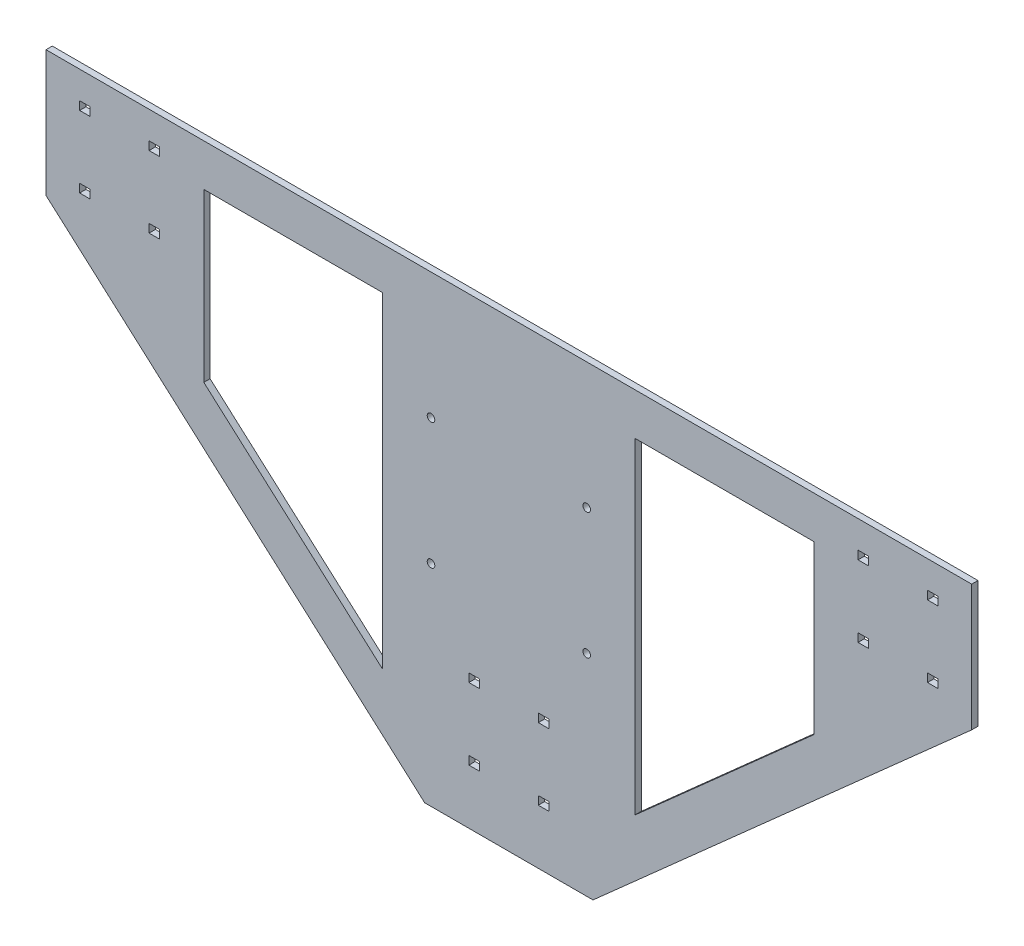
from build123d import *

# Parameters (mm, degrees)
BOSS_EXTRU_1_DEPTH      = 3
ESQUISSE2_W             = 5
ESQUISSE2_H             = 4
ENL_V_MAT_EXTRU_1_DEPTH = 3
ESQUISSE4_R             = 1.8
ENL_V_MAT_EXTRU_2_DEPTH = 3
ENL_V_MAT_EXTRU_3_DEPTH = 3


with BuildPart() as part:
    # Esquisse1 → Boss.-Extru.1 (new body)
    with BuildSketch(Plane.XY):
        Polygon((-220, 50), (-40, -110), (40, -110), (220, 50), (220, 110), (-220, 110), align=None)
    extrude(amount=BOSS_EXTRU_1_DEPTH)

    # Esquisse2 → Enlèv. mat.-Extru.1 (cut)
    with BuildSketch(Plane(origin=(0, 0, 0), x_dir=(-1, 0, 0), z_dir=(0, 0, -1))):
        with Locations((-201.5, 95)):
            Rectangle(ESQUISSE2_W, ESQUISSE2_H)
        with Locations((-168.5, 95)):
            Rectangle(ESQUISSE2_W, ESQUISSE2_H)
        with Locations((-168.5, 61)):
            Rectangle(ESQUISSE2_W, ESQUISSE2_H)
        with Locations((-201.5, 61)):
            Rectangle(ESQUISSE2_W, ESQUISSE2_H)
        with Locations((168.5, 61)):
            Rectangle(ESQUISSE2_W, ESQUISSE2_H)
        with Locations((201.5, 61)):
            Rectangle(ESQUISSE2_W, ESQUISSE2_H)
        with Locations((168.5, 95)):
            Rectangle(ESQUISSE2_W, ESQUISSE2_H)
        with Locations((201.5, 95)):
            Rectangle(ESQUISSE2_W, ESQUISSE2_H)
        with Locations((-16.5, -48)):
            Rectangle(ESQUISSE2_W, ESQUISSE2_H)
        with Locations((16.5, -48)):
            Rectangle(ESQUISSE2_W, ESQUISSE2_H)
        with Locations((16.5, -82)):
            Rectangle(ESQUISSE2_W, ESQUISSE2_H)
        with Locations((-16.5, -82)):
            Rectangle(ESQUISSE2_W, ESQUISSE2_H)
    extrude(amount=-ENL_V_MAT_EXTRU_1_DEPTH, mode=Mode.SUBTRACT)

    # Esquisse4 → Enlèv. mat.-Extru.2 (cut)
    with BuildSketch(Plane.XY.offset(3)):
        with Locations((-37, 50)):
            Circle(ESQUISSE4_R)
        with Locations((37, 50)):
            Circle(ESQUISSE4_R)
        with Locations((-37, -10)):
            Circle(ESQUISSE4_R)
        with Locations((37, -10)):
            Circle(ESQUISSE4_R)
    extrude(amount=-ENL_V_MAT_EXTRU_2_DEPTH, mode=Mode.SUBTRACT)

    # Esquisse5 → Enlèv. mat.-Extru.3 (cut)
    with BuildSketch(Plane.XY.offset(3)):
        Polygon((-145, 90), (-60, 90), (-60, -65), (-145, 10.555555556), align=None)
        Polygon((145, 90), (60, 90), (60, -65), (145, 10.555555556), align=None)
    extrude(amount=-ENL_V_MAT_EXTRU_3_DEPTH, mode=Mode.SUBTRACT)


solid = part.part
